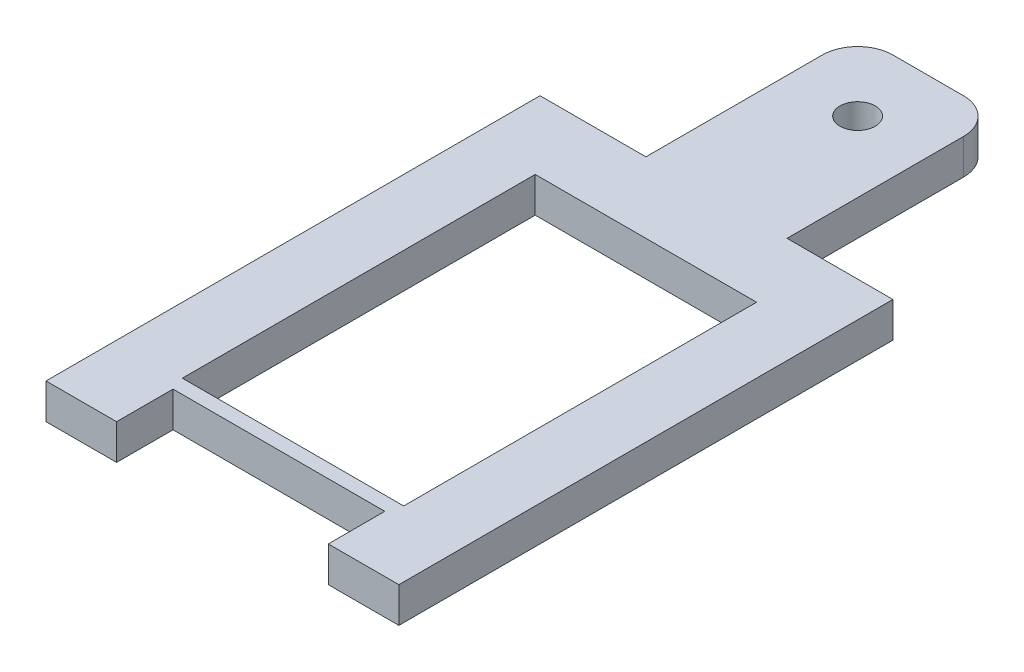
from build123d import *

# Parameters (mm, degrees)
SKETCH1_R           = 0.635
SKETCH1_W           = 7.96592112
SKETCH1_H           = 12.7
BOSS_EXTRUDE1_DEPTH = 1.27


with BuildPart() as part:
    # Sketch1 → Boss-Extrude1 (new body)
    with BuildSketch(Plane(origin=(0, 0, 0), x_dir=(1, 0, 0), z_dir=(0, 1, 0))):
        with BuildLine():
            Line((6.35, -8.89), (6.35, 8.89))
            Line((6.35, 8.89), (2.54, 8.89))
            Line((2.54, 8.89), (2.54, 15.24))
            ThreePointArc((2.54, 15.24), (2.168025612, 16.138025612), (1.27, 16.51))
            Line((1.27, 16.51), (-1.27, 16.51))
            ThreePointArc((-1.27, 16.51), (-2.168025612, 16.138025612), (-2.54, 15.24))
            Line((-2.54, 15.24), (-2.54, 8.89))
            Line((-2.54, 8.89), (-6.35, 8.89))
            Line((-6.35, 8.89), (-6.35, -8.89))
            Line((-6.35, -8.89), (-3.81, -8.89))
            Line((-3.81, -8.89), (-3.81, -6.858))
            Line((-3.81, -6.858), (3.81, -6.858))
            Line((3.81, -6.858), (3.81, -8.89))
            Line((3.81, -8.89), (6.35, -8.89))
        make_face()
        with Locations((0, 13.97)):
            Circle(SKETCH1_R, mode=Mode.SUBTRACT)
        Rectangle(SKETCH1_W, SKETCH1_H, mode=Mode.SUBTRACT)
    extrude(amount=BOSS_EXTRUDE1_DEPTH)


solid = part.part
